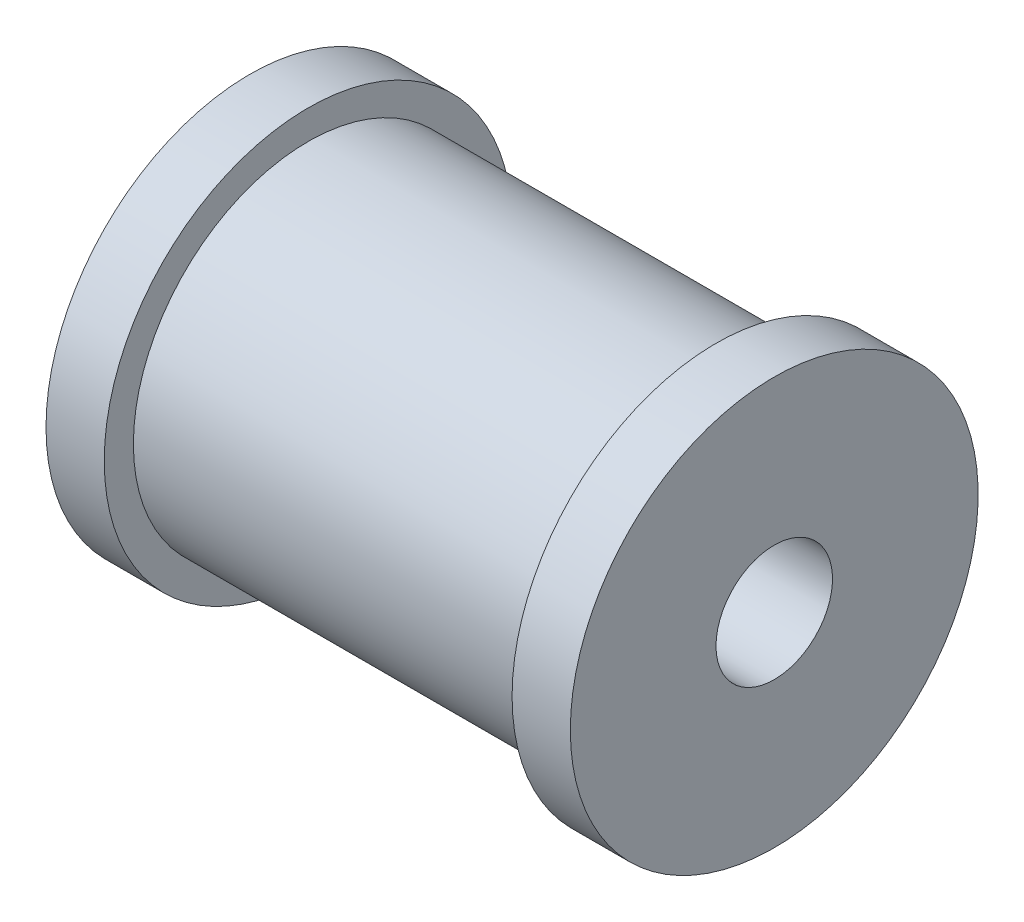
from build123d import *


with BuildPart() as part:
    # Sketch2 → Revolve1 (revolve)
    with BuildSketch(Plane.XY):
        Polygon((0, 2), (0, 7), (2, 7), (2, 6), (16, 6), (16, 7), (18, 7), (18, 2), align=None)
    revolve(axis=Axis((0, 0, 0), (1, 0, 0)))


solid = part.part
